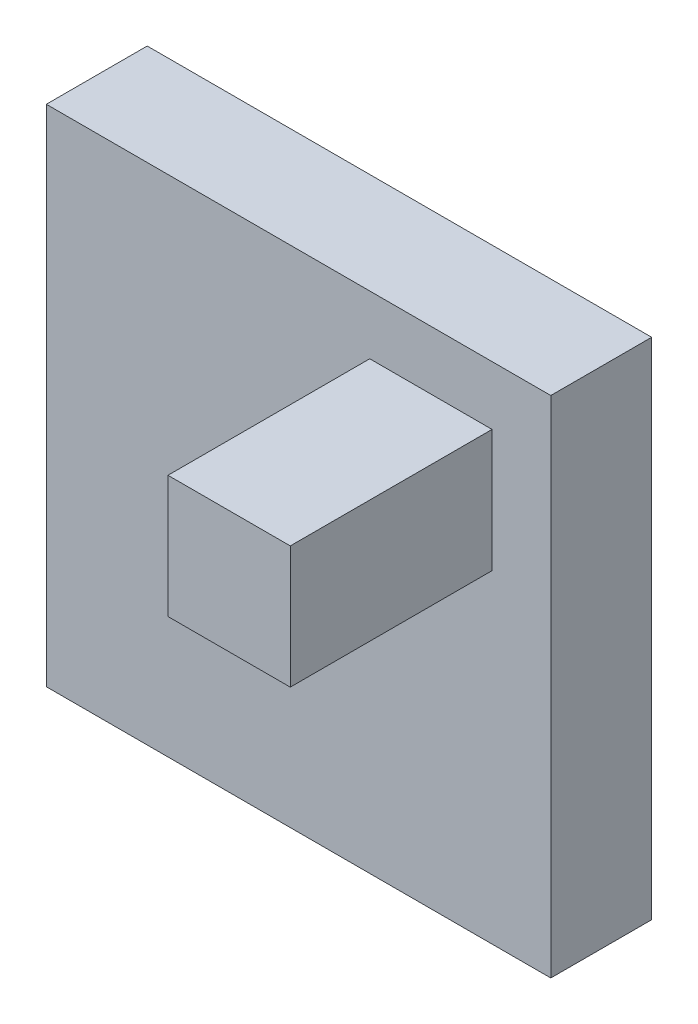
from build123d import *

# Parameters (mm, degrees)
SKETCH1_W           = 10
SKETCH1_H           = 10
BOSS_EXTRUDE1_DEPTH = 2
SKETCH2_W           = 2.424732092
SKETCH2_H           = 2.424732092
BOSS_EXTRUDE2_DEPTH = 4


with BuildPart() as part:
    # Sketch1 → Boss-Extrude1 (new body)
    with BuildSketch(Plane.XY):
        with Locations((5, -5)):
            Rectangle(SKETCH1_W, SKETCH1_H)
    extrude(amount=BOSS_EXTRUDE1_DEPTH)

    # Sketch2 → Boss-Extrude2 (add)
    with BuildSketch(Plane.XY.offset(2)):
        with Locations((7.623698074, -2.376301926)):
            Rectangle(SKETCH2_W, SKETCH2_H)
    extrude(amount=BOSS_EXTRUDE2_DEPTH)


solid = part.part
